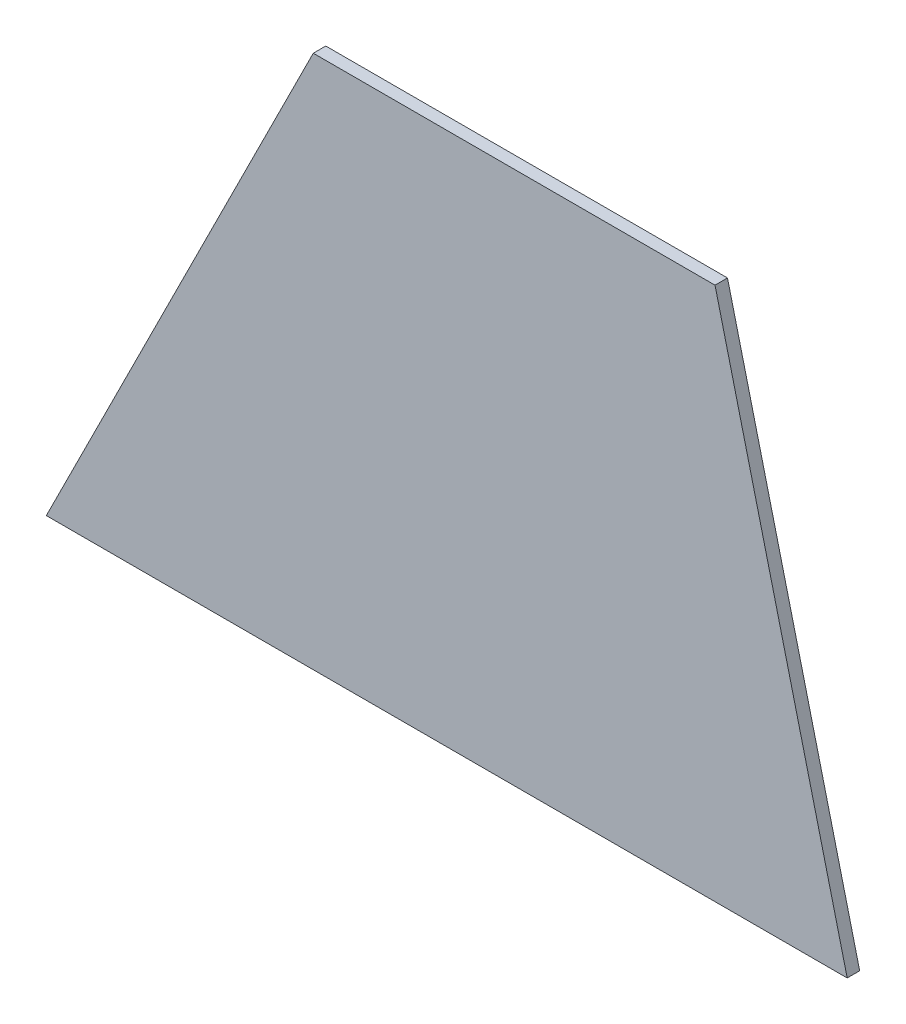
from build123d import *

# Parameters (mm, degrees)
BOSS_EXTRUDE1_DEPTH = 4.7498


with BuildPart() as part:
    # Sketch1 → Boss-Extrude1 (new body)
    with BuildSketch(Plane.XY):
        Polygon((-217.714285714, -58.057142857), (87.085714286, -58.057142857), (36.777714408, 145.142857143), (-116.114285714, 145.142857143), align=None)
    extrude(amount=BOSS_EXTRUDE1_DEPTH)


solid = part.part
